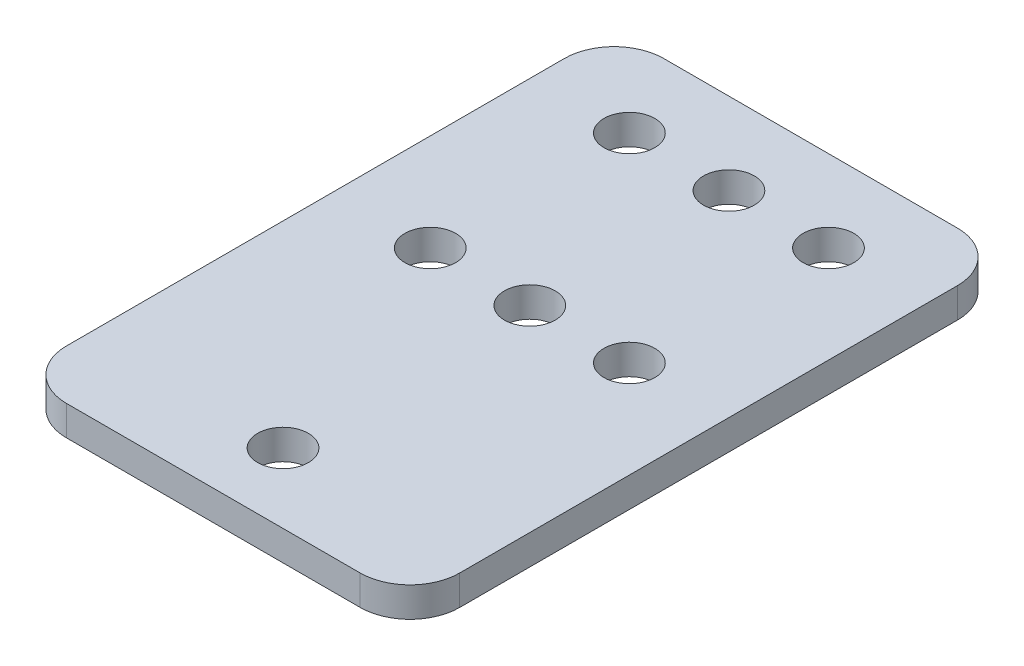
from build123d import *

# Parameters (mm, degrees)
SKETCH1_W                 = 39.5
SKETCH1_H                 = 60
BOSS_EXTRUDE1_DEPTH       = 3
SKETCH2_R                 = 2.55
CUT_EXTRUDE1_DEPTH        = 4
SKETCH4_R                 = 2.55
CUT_EXTRUDE2_DEPTH        = 4
LPATTERN1_COUNT           = 2
LPATTERN1_PITCH           = 10
LPATTERN1_COL_COUNT       = 2
LPATTERN1_COL_PITCH       = 10
LPATTERN2_COUNT           = 2
LPATTERN2_PITCH           = 20
LPATTERN2_COPY_1_SKETCH_R = 2.55
LPATTERN2_COPY_1_DEPTH    = 4
LPATTERN2_COPY_2_SKETCH_R = 2.55
LPATTERN2_COPY_2_DEPTH    = 4
FILLET1_R                 = 5
FILLET2_R                 = 5
FILLET3_R                 = 5
FILLET4_R                 = 5


with BuildPart() as part:
    # Sketch1 → Boss-Extrude1 (new body)
    with BuildSketch(Plane(origin=(0, 0, 0), x_dir=(1, 0, 0), z_dir=(0, 1, 0))):
        Rectangle(SKETCH1_W, SKETCH1_H)
    extrude(amount=BOSS_EXTRUDE1_DEPTH)

    # Sketch2 → Cut-Extrude1 (cut, through all)
    with BuildSketch(Plane(origin=(0, 3, 0), x_dir=(1, 0, 0), z_dir=(0, 1, 0))):
        with Locations((0, 21.79)):
            Circle(SKETCH2_R)
    cut_extrude1 = extrude(amount=-CUT_EXTRUDE1_DEPTH, mode=Mode.SUBTRACT)

    # Sketch4 → Cut-Extrude2 (cut, through all)
    with BuildSketch(Plane(origin=(0, 3, 0), x_dir=(1, 0, 0), z_dir=(0, 1, 0))):
        with Locations((0, -23)):
            Circle(SKETCH4_R)
    extrude(amount=-CUT_EXTRUDE2_DEPTH, mode=Mode.SUBTRACT)

    # LPattern1: Cut-Extrude1 ×2
    with Locations(*[(-i * LPATTERN1_PITCH, 0, 0) for i in range(1, LPATTERN1_COUNT)]):
        add(cut_extrude1, mode=Mode.SUBTRACT)

    # LPattern1 col: Cut-Extrude1 ×2
    with Locations(*[(i * LPATTERN1_COL_PITCH, 0, 0) for i in range(1, LPATTERN1_COL_COUNT)]):
        add(cut_extrude1, mode=Mode.SUBTRACT)

    # LPattern2: Cut-Extrude1 ×2
    with Locations(*[(0, 0, i * LPATTERN2_PITCH) for i in range(1, LPATTERN2_COUNT)]):
        add(cut_extrude1, mode=Mode.SUBTRACT)

    # LPattern2 copy 1 sketch → LPattern2 copy 1 (cut, through all)
    with BuildSketch(Plane(origin=(-10, 3, 20), x_dir=(1, 0, 0), z_dir=(0, 1, 0))):
        with Locations((0, 21.79)):
            Circle(LPATTERN2_COPY_1_SKETCH_R)
    extrude(amount=-LPATTERN2_COPY_1_DEPTH, mode=Mode.SUBTRACT)

    # LPattern2 copy 2 sketch → LPattern2 copy 2 (cut, through all)
    with BuildSketch(Plane(origin=(10, 3, 20), x_dir=(1, 0, 0), z_dir=(0, 1, 0))):
        with Locations((0, 21.79)):
            Circle(LPATTERN2_COPY_2_SKETCH_R)
    extrude(amount=-LPATTERN2_COPY_2_DEPTH, mode=Mode.SUBTRACT)

    # Fillet1
    fillet1_edges = [part.edges().sort_by_distance(p)[0] for p in [
        (-19.75, 1.5, 30),
    ]]
    fillet(fillet1_edges, radius=FILLET1_R)

    # Fillet2
    fillet2_edges = [part.edges().sort_by_distance(p)[0] for p in [
        (19.75, 1.5, -30),
    ]]
    fillet(fillet2_edges, radius=FILLET2_R)

    # Fillet3
    fillet3_edges = [part.edges().sort_by_distance(p)[0] for p in [
        (19.75, 1.5, 30),
    ]]
    fillet(fillet3_edges, radius=FILLET3_R)

    # Fillet4
    fillet4_edges = [part.edges().sort_by_distance(p)[0] for p in [
        (-19.75, 1.5, -30),
    ]]
    fillet(fillet4_edges, radius=FILLET4_R)


solid = part.part
